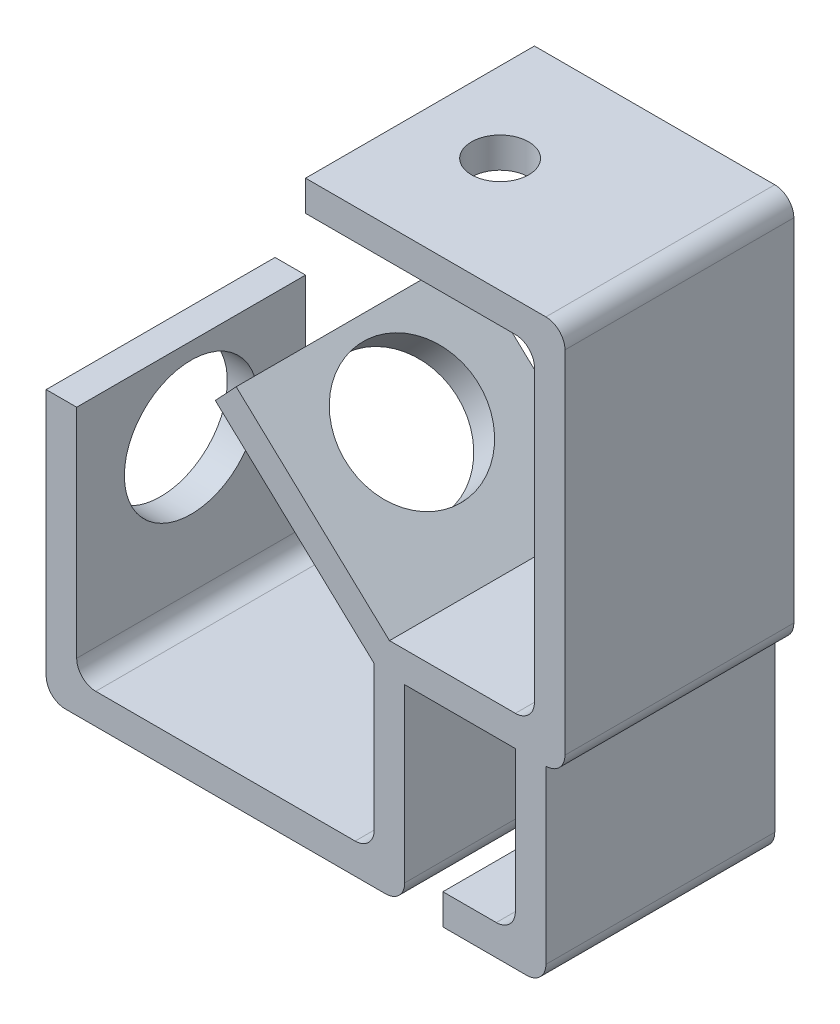
from build123d import *

# Parameters (mm, degrees)
BOSS_EXTRUDE3_DEPTH = 30
SKETCH10_R          = 17.5
CUT_EXTRUDE1_DEPTH  = 8
SKETCH11_R          = 17.5
CUT_EXTRUDE2_DEPTH  = 8
FILLET3_R           = 5
FILLET4_R           = 5
SKETCH12_R          = 7.5
CUT_EXTRUDE3_DEPTH  = 10


with BuildPart() as part:
    # Sketch3 → Boss-Extrude3 (new body, symmetric)
    with BuildSketch(Plane.XY):
        with BuildLine():
            Line((0, 0), (-41.650922989, 38.912730747))
            Line((-41.650922989, 38.912730747), (-36.189487094, 44.758474324))
            Line((-36.189487094, 44.758474324), (4, 7.211102551))
            Line((4, 7.211102551), (37, 7.211102551))
            ThreePointArc((37, 7.211102551), (40.535533906, 8.675568645), (42, 12.211102551))
            Line((42, 12.211102551), (42, 88.211102551))
            ThreePointArc((42, 88.211102551), (40.535533906, 91.746636457), (37, 93.211102551))
            Line((37, 93.211102551), (-18, 93.211102551))
            Line((-18, 93.211102551), (-18, 101.211102551))
            Line((-18, 101.211102551), (45, 101.211102551))
            ThreePointArc((45, 101.211102551), (48.535533906, 99.746636457), (50, 96.211102551))
            Line((50, 96.211102551), (50, 4.211102551))
            ThreePointArc((50, 4.211102551), (48.535533906, 0.675568645), (45, -0.788897449))
            Line((45, -0.788897449), (45, -45.788897449))
            ThreePointArc((45, -45.788897449), (43.535533906, -49.324431355), (40, -50.788897449))
            Line((40, -50.788897449), (18, -50.788897449))
            Line((18, -50.788897449), (18, -42.788897449))
            Line((18, -42.788897449), (32, -42.788897449))
            ThreePointArc((32, -42.788897449), (35.535533906, -41.324431355), (37, -37.788897449))
            Line((37, -37.788897449), (37, -0.788897449))
            Line((37, -0.788897449), (8, -0.788897449))
            Line((8, -0.788897449), (8, -45.788897449))
            ThreePointArc((8, -45.788897449), (6.535533906, -49.324431355), (3, -50.788897449))
            Line((3, -50.788897449), (-86, -50.788897449))
            Line((-86, -50.788897449), (-86, 19.211102551))
            Line((-86, 19.211102551), (-78, 19.211102551))
            Line((-78, 19.211102551), (-78, -42.788897449))
            Line((-78, -42.788897449), (-5, -42.788897449))
            ThreePointArc((-5, -42.788897449), (-1.464466094, -41.324431355), (0, -37.788897449))
            Line((0, -37.788897449), (0, 0))
        make_face()
    extrude(amount=BOSS_EXTRUDE3_DEPTH, both=True)

    # Sketch10 → Cut-Extrude1 (cut)
    with BuildSketch(Plane(origin=(0, 0, 0), x_dir=(0, 0, 1), z_dir=(-0.682679487, -0.730717947, 0))):
        with Locations((0, 35)):
            Circle(SKETCH10_R)
    extrude(amount=-CUT_EXTRUDE1_DEPTH, mode=Mode.SUBTRACT)

    # Sketch11 → Cut-Extrude2 (cut)
    with BuildSketch(Plane.ZY.offset(86)):
        with Locations((0, -2.6)):
            Circle(SKETCH11_R)
    extrude(amount=-CUT_EXTRUDE2_DEPTH, mode=Mode.SUBTRACT)

    # Fillet3
    fillet3_edges = [part.edges().sort_by_distance(p)[0] for p in [
        (-78, -42.788897449, 0),
    ]]
    fillet(fillet3_edges, radius=FILLET3_R)

    # Fillet4
    fillet4_edges = [part.edges().sort_by_distance(p)[0] for p in [
        (-86, -50.788897449, 0),
    ]]
    fillet(fillet4_edges, radius=FILLET4_R)

    # Sketch12 → Cut-Extrude3 (cut)
    with BuildSketch(Plane(origin=(0, 101.211102551, 0), x_dir=(1, 0, 0), z_dir=(0, 1, 0))):
        with Locations((3, 0)):
            Circle(SKETCH12_R)
    extrude(amount=-CUT_EXTRUDE3_DEPTH, mode=Mode.SUBTRACT)


solid = part.part
